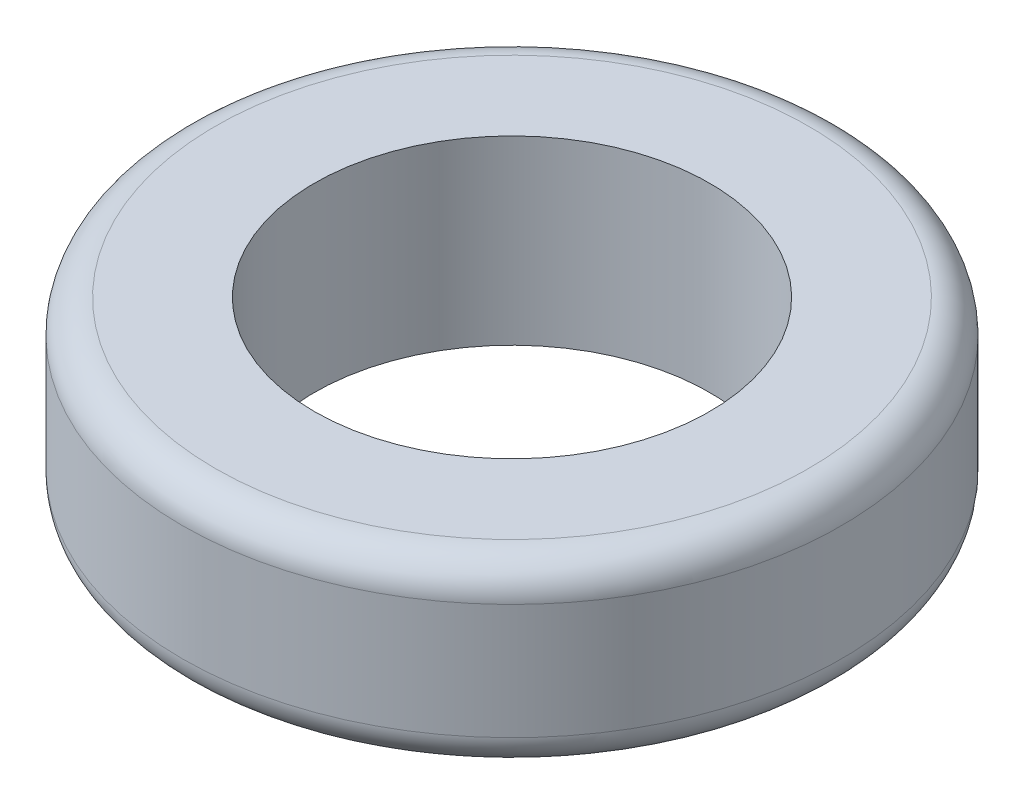
from build123d import *

# Parameters (mm, degrees)
SKETCH1_R           = 10
SKETCH1_R_2         = 6
BOSS_EXTRUDE1_DEPTH = 5.5
FILLET1_R           = 1


with BuildPart() as part:
    # Sketch1 → Boss-Extrude1 (new body)
    with BuildSketch(Plane(origin=(0, 0, 0), x_dir=(1, 0, 0), z_dir=(0, 1, 0))):
        Circle(SKETCH1_R)
        Circle(SKETCH1_R_2, mode=Mode.SUBTRACT)
    extrude(amount=BOSS_EXTRUDE1_DEPTH)

    # Fillet1
    fillet1_edges = [part.edges().sort_by_distance(p)[0] for p in [
        (-10, 0, 0),
        (-10, 5.5, 0),
    ]]
    fillet(fillet1_edges, radius=FILLET1_R)


solid = part.part
